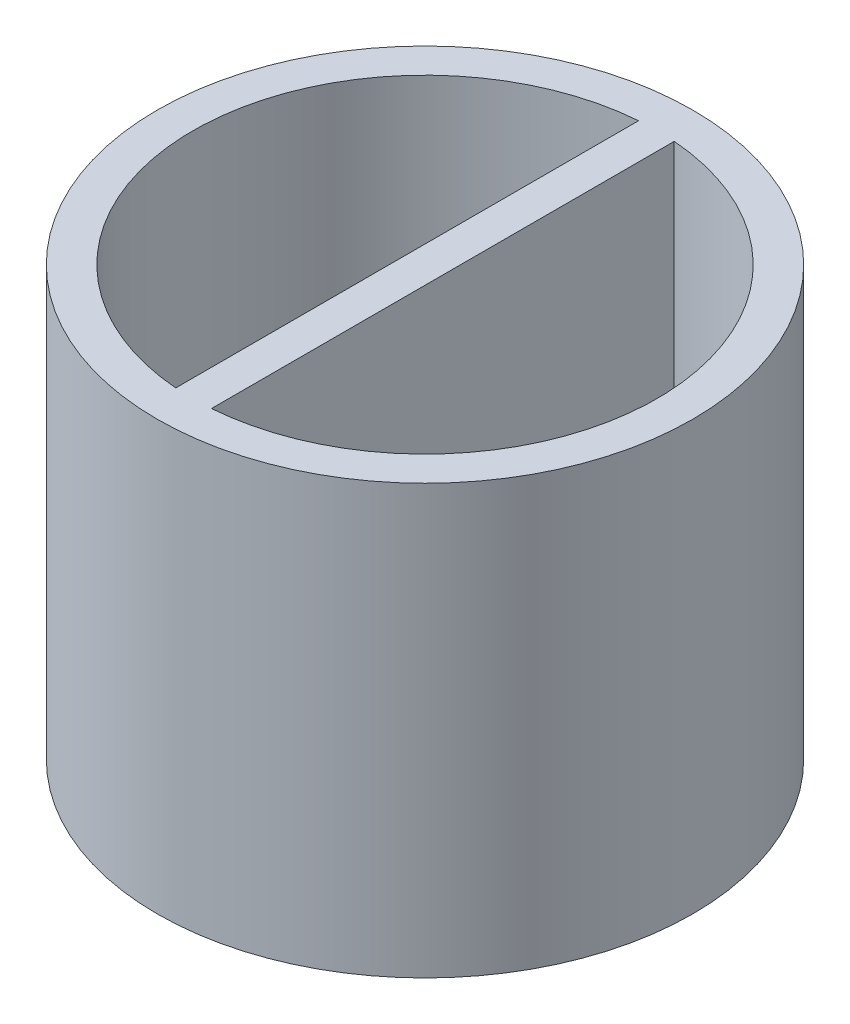
from build123d import *

# Parameters (mm, degrees)
SKETCH1_R           = 37.5
BOSS_EXTRUDE1_DEPTH = 60
CUT_EXTRUDE1_DEPTH  = 50
SKETCH3_R           = 10.35
CUT_EXTRUDE2_DEPTH  = 5


with BuildPart() as part:
    # Sketch1 → Boss-Extrude1 (new body)
    with BuildSketch(Plane(origin=(0, 0, 0), x_dir=(1, 0, 0), z_dir=(0, 1, 0))):
        Circle(SKETCH1_R)
    extrude(amount=BOSS_EXTRUDE1_DEPTH)

    # Sketch2 → Cut-Extrude1 (cut)
    with BuildSketch(Plane(origin=(0, 60, 0), x_dir=(1, 0, 0), z_dir=(0, 1, 0))):
        with BuildLine():
            Line((-2.5, -32.403703492), (-2.5, 32.403703492))
            ThreePointArc((-2.5, 32.403703492), (-32.5, 0), (-2.5, -32.403703492))
        make_face()
        with BuildLine():
            ThreePointArc((32.5, 0), (23.848480035, 22.079402166), (2.5, 32.403703492))
            Line((2.5, 32.403703492), (2.5, -32.403703492))
            ThreePointArc((2.5, -32.403703492), (23.848480035, -22.079402166), (32.5, 0))
        make_face()
    extrude(amount=-CUT_EXTRUDE1_DEPTH, mode=Mode.SUBTRACT)

    # Sketch3 → Cut-Extrude2 (cut)
    with BuildSketch(Plane.XZ):
        Circle(SKETCH3_R)
    extrude(amount=-CUT_EXTRUDE2_DEPTH, mode=Mode.SUBTRACT)


solid = part.part
